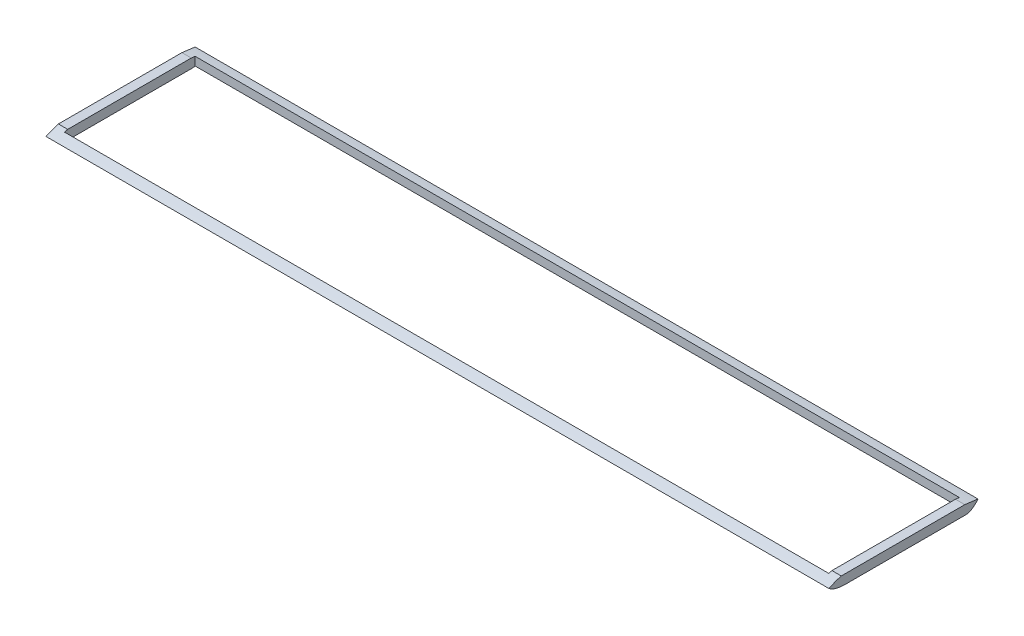
from build123d import *

# Parameters (mm, degrees)
SKETCH1_W           = 6.35
SKETCH1_H           = 88.9
SKETCH1_W_2         = 533.4
SKETCH1_H_2         = 6.35
BOSS_EXTRUDE1_DEPTH = 6.35
CUT_EXTRUDE1_DEPTH  = 534.4


with BuildPart() as part:
    # Sketch1 → Boss-Extrude1 (new body)
    with BuildSketch(Plane(origin=(0, 0, 0), x_dir=(1, 0, 0), z_dir=(0, 1, 0))):
        with Locations((-530.225, -44.45)):
            Rectangle(SKETCH1_W, SKETCH1_H)
        Polygon((-6.35, -95.25), (-6.35, -88.9), (-527.05, -88.9), (-533.4, -88.9), (-533.4, -95.25), align=None)
        with Locations((-266.7, 3.175)):
            Rectangle(SKETCH1_W_2, SKETCH1_H_2)
        Polygon((0, -95.25), (0, 0), (-6.35, 0), (-6.35, -88.9), (-6.35, -95.25), align=None)
    extrude(amount=BOSS_EXTRUDE1_DEPTH)

    # Sketch3 → Cut-Extrude1 (cut, through all)
    with BuildSketch(Plane(origin=(0, 0, 0), x_dir=(0, 0, -1), z_dir=(1, 0, 0))):
        with BuildLine():
            Line((-84.641073093, 0), (-84.641073093, -18.612237469))
            Line((-84.641073093, -18.612237469), (-110.014683452, -18.612237469))
            Line((-110.014683452, -18.612237469), (-110.014683452, 30.772943851))
            Line((-110.014683452, 30.772943851), (12.985283774, 30.772943851))
            Line((12.985283774, 30.772943851), (12.985283774, -18.612237469))
            Line((12.985283774, -18.612237469), (-2.570953077, -18.612237469))
            Line((-2.570953077, -18.612237469), (-2.570953077, 0))
            add(Edge.make_bspline(
                [(6.35, 5.188130384), (2.022123536, -0.282902935), (-2.570953077, 0)],
                knots=[0, 0, 0, 1, 1, 1], degree=2))
            add(Edge.make_bspline(
                [(-95.25, 3.175), (-82.381101325, 9.220365094), (-50.77888694, 8.736493451), (-10.422216495, 7.851149063), (6.35, 5.188130384)],
                knots=[0, 0, 0, 0, 0.37290812, 1, 1, 1, 1], degree=3))
            add(Edge.make_bspline(
                [(-95.25, 3.175), (-91.544297235, 0.114428997), (-84.641073093, 0)],
                knots=[0, 0, 0, 1, 1, 1], degree=2))
        make_face()
    extrude(amount=-CUT_EXTRUDE1_DEPTH, mode=Mode.SUBTRACT)


solid = part.part
